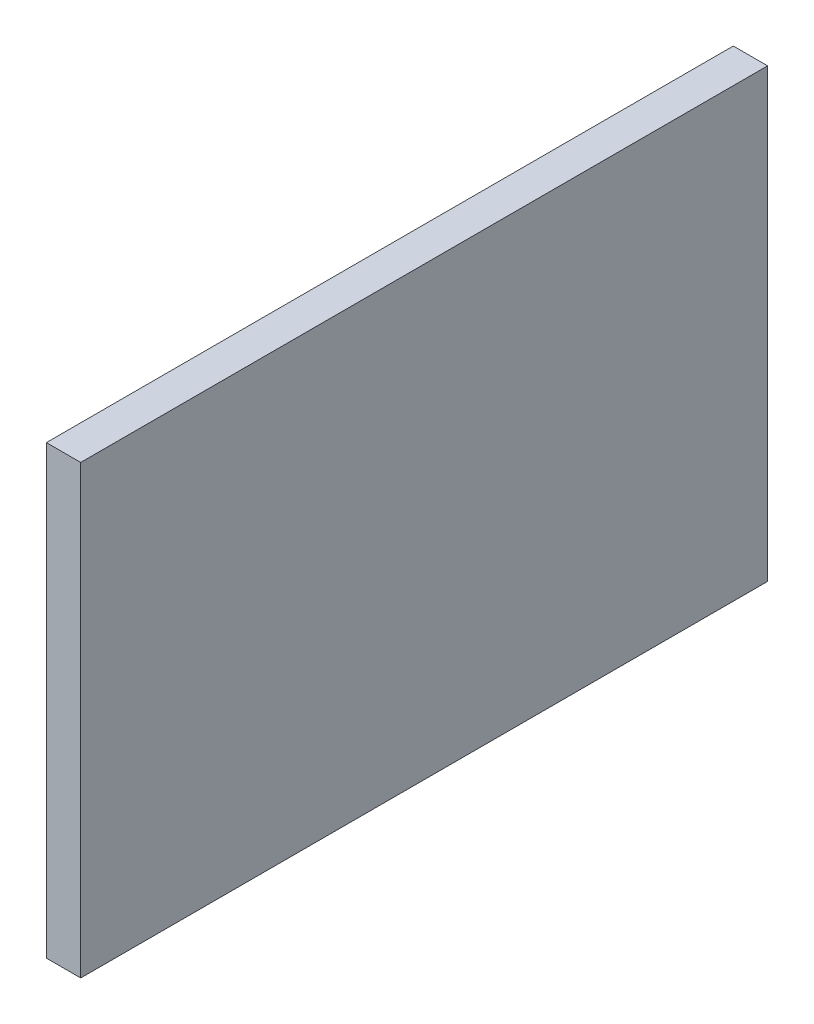
from build123d import *

# Parameters (mm, degrees)
SKETCH1_W           = 508
SKETCH1_H           = 330.2
BOSS_EXTRUDE1_DEPTH = 25.4
SKETCH3_R           = 12.7
CUT_EXTRUDE2_DEPTH  = 6.35


with BuildPart() as part:
    # Sketch1 → Boss-Extrude1 (new body)
    with BuildSketch(Plane(origin=(0, 0, 0), x_dir=(0, 0, -1), z_dir=(1, 0, 0))):
        with Locations((-212.818382353, -138.299264706)):
            Rectangle(SKETCH1_W, SKETCH1_H)
    extrude(amount=BOSS_EXTRUDE1_DEPTH)

    # Sketch3 → Cut-Extrude2 (cut)
    with BuildSketch(Plane.ZY):
        with Locations((9.618382353, -23.999264706)):
            Circle(SKETCH3_R)
    extrude(amount=-CUT_EXTRUDE2_DEPTH, mode=Mode.SUBTRACT)


solid = part.part
